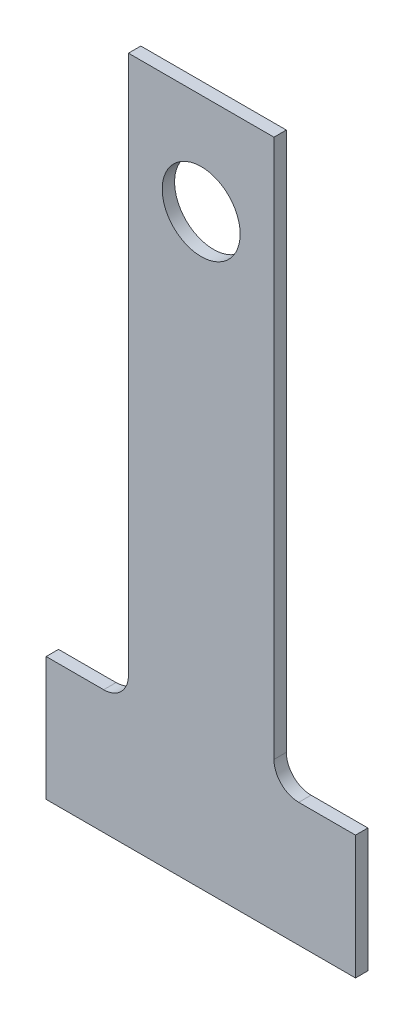
from build123d import *

# Parameters (mm, degrees)
DODANIE_WYCI_GNI_CIE1_DEPTH = 1
SZKIC2_R                    = 3.15
WYTNIJ_WYCI_GNI_CIE1_DEPTH  = 1


with BuildPart() as part:
    # Szkic1 → Dodanie-wyciągnięcie1 (new body)
    with BuildSketch(Plane.XY):
        with BuildLine():
            Line((-12.5, -6), (-12.5, -16))
            Line((-12.5, -16), (12.5, -16))
            Line((12.5, -16), (12.5, -6))
            Line((12.5, -6), (7.91, -6))
            ThreePointArc((7.91, -6), (6.495786438, -5.414213562), (5.91, -4))
            Line((5.91, -4), (5.91, 5.45))
            Line((5.91, 5.45), (5.91, 39.55))
            Line((5.91, 39.55), (-5.85, 39.55))
            Line((-5.85, 39.55), (-5.85, 5.45))
            Line((-5.85, 5.45), (-5.85, -4))
            ThreePointArc((-5.85, -4), (-6.435786438, -5.414213562), (-7.85, -6))
            Line((-7.85, -6), (-12.5, -6))
        make_face()
    extrude(amount=DODANIE_WYCI_GNI_CIE1_DEPTH)

    # Szkic2 → Wytnij-wyciągnięcie1 (cut)
    with BuildSketch(Plane.XY.offset(1)):
        with Locations((0.03, 31.4)):
            Circle(SZKIC2_R)
    extrude(amount=-WYTNIJ_WYCI_GNI_CIE1_DEPTH, mode=Mode.SUBTRACT)


solid = part.part
